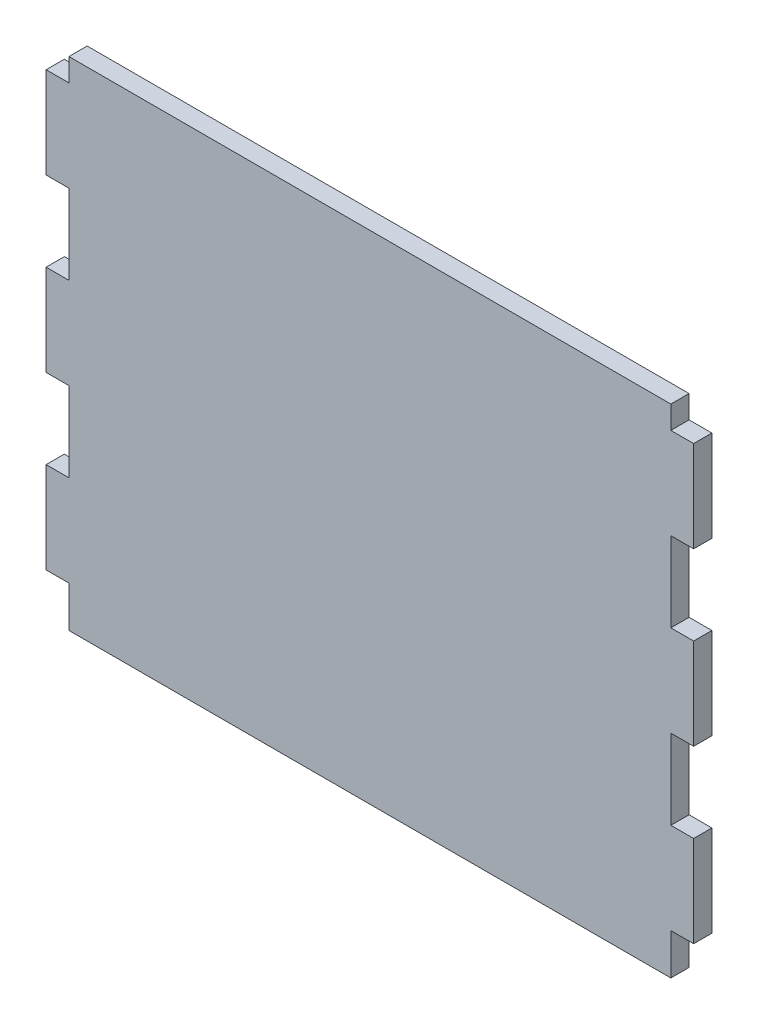
from build123d import *

# Parameters (mm, degrees)
BOSS_EXTRUDE1_DEPTH = 5.08


with BuildPart() as part:
    # Sketch1 → Boss-Extrude1 (new body)
    with BuildSketch(Plane.XY):
        Polygon((83.82, -69.215), (-83.82, -69.215), (-83.82, -57.785), (-90.17, -57.785), (-90.17, -32.385), (-83.82, -32.385), (-83.82, -10.16), (-90.17, -10.16), (-90.17, 15.24), (-83.82, 15.24), (-83.82, 37.465), (-90.17, 37.465), (-90.17, 62.865), (-83.82, 62.865), (-83.82, 69.215), (83.82, 69.215), (83.82, 62.865), (90.17, 62.865), (90.17, 37.465), (83.82, 37.465), (83.82, 15.24), (90.17, 15.24), (90.17, -10.16), (83.82, -10.16), (83.82, -32.385), (90.17, -32.385), (90.17, -57.785), (83.82, -57.785), align=None)
    extrude(amount=BOSS_EXTRUDE1_DEPTH)


solid = part.part
